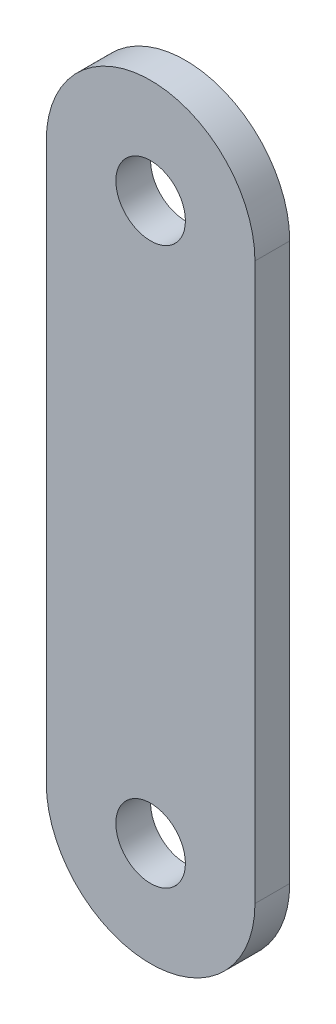
from build123d import *

# Parameters (mm, degrees)
SKETCH2_R           = 3.175
BOSS_EXTRUDE1_DEPTH = 1.5875


with BuildPart() as part:
    # Sketch2 → Boss-Extrude1 (new body, symmetric)
    with BuildSketch(Plane.XY):
        with BuildLine():
            Line((-9.525, 25.4), (-9.525, -25.4))
            ThreePointArc((-9.525, -25.4), (0, -34.925), (9.525, -25.4))
            Line((9.525, -25.4), (9.525, 25.4))
            ThreePointArc((9.525, 25.4), (0, 34.925), (-9.525, 25.4))
        make_face()
        with Locations((0, 25.4)):
            Circle(SKETCH2_R, mode=Mode.SUBTRACT)
        with Locations((0, -25.4)):
            Circle(SKETCH2_R, mode=Mode.SUBTRACT)
    extrude(amount=BOSS_EXTRUDE1_DEPTH, both=True)


solid = part.part
